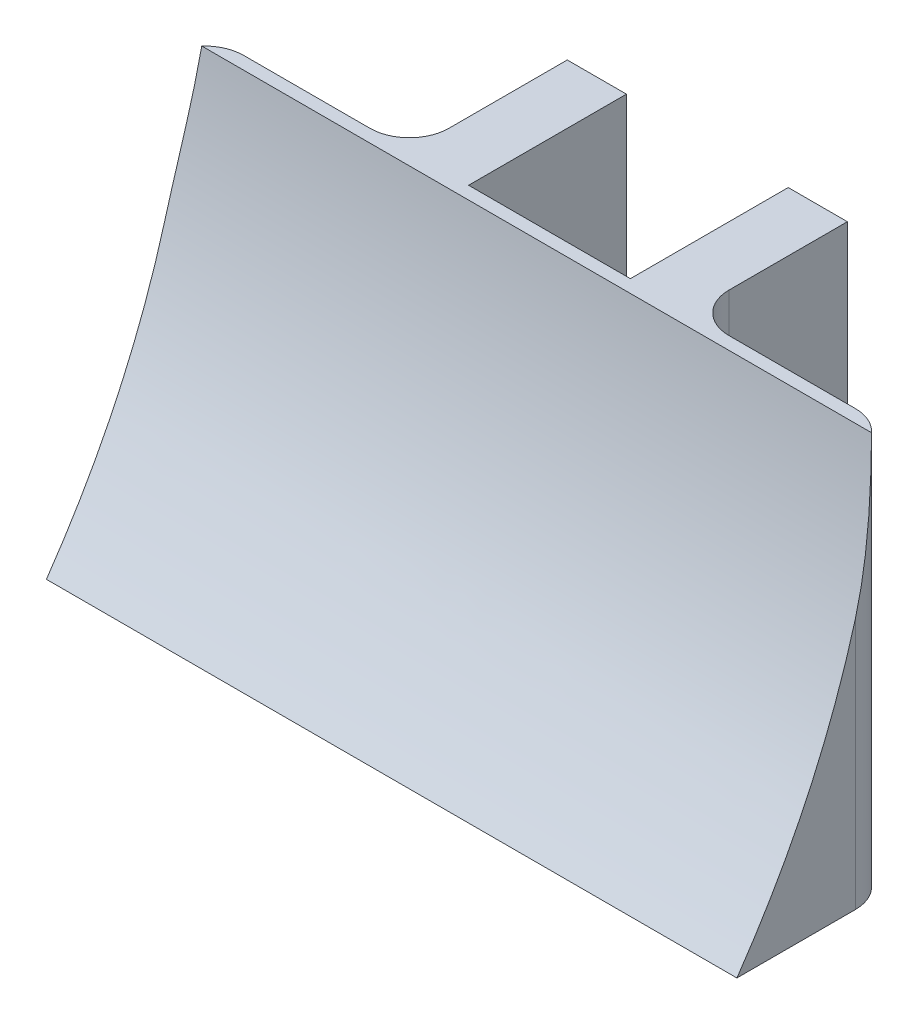
from build123d import *

# Parameters (mm, degrees)
SKETCH2_W             = 3
SKETCH2_H             = 20
BOSS_EXTRUDE1_DEPTH   = 8
BOSS_EXTRUDE1_2_DEPTH = 8
SKETCH3_W             = 35
SKETCH3_H             = 20
BOSS_EXTRUDE2_DEPTH   = 8
CUT_EXTRUDE1_DEPTH    = 100
FILLET1_R             = 2


with BuildPart() as part:
    # Sketch2 → Boss-Extrude1 (new body)
    with BuildSketch(Plane.XY):
        with Locations((-5.6, 0)):
            Rectangle(SKETCH2_W, SKETCH2_H)
    extrude(amount=BOSS_EXTRUDE1_DEPTH)



with BuildPart() as body_2:
    # Sketch2 → Boss-Extrude1 2 (new body)
    with BuildSketch(Plane.XY):
        with Locations((5.6, 0)):
            Rectangle(SKETCH2_W, SKETCH2_H)
    extrude(amount=BOSS_EXTRUDE1_2_DEPTH)


with BuildPart() as part_1:
    add(part.part)

    add(body_2.part)  # Boss-Extrude2 merges body 2
    # Sketch3 → Boss-Extrude2 (add)
    with BuildSketch(Plane.XY.offset(8)):
        Rectangle(SKETCH3_W, SKETCH3_H)
    extrude(amount=BOSS_EXTRUDE2_DEPTH)

    # Sketch4 → Cut-Extrude1 (cut)
    with BuildSketch(Plane(origin=(17.5, 0, 0), x_dir=(0, 0, -1), z_dir=(1, 0, 0))):
        with BuildLine():
            Line((-8.650350687, 10), (-18.749318475, 11.146699317))
            Line((-18.749318475, 11.146699317), (-17.556068679, -8.149022999))
            Line((-17.556068679, -8.149022999), (-16, -10))
            add(Edge.make_bspline(
                [(-8.650350687, 10), (-9.760639053, -0.993319635), (-16, -10)],
                knots=[0, 0, 0, 1, 1, 1], degree=2))
        make_face()
    extrude(amount=-CUT_EXTRUDE1_DEPTH, mode=Mode.SUBTRACT)

    # Fillet1
    fillet1_edges = [part_1.edges().sort_by_distance(p)[0] for p in [
        (17.5, 0, 8),
        (-17.5, 0, 8),
        (-7.1, 0, 8),
        (7.1, 0, 8),
    ]]
    fillet(fillet1_edges, radius=FILLET1_R)


solid = part_1.part
